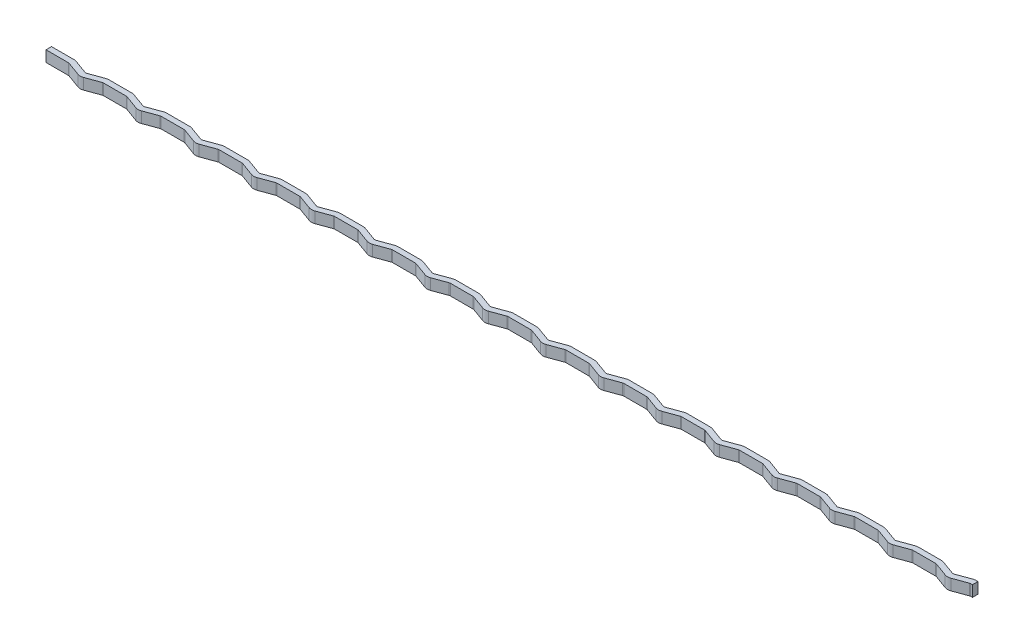
from build123d import *

# Parameters (mm, degrees)
BOSS_EXTRUDE1_DEPTH = 2
LPATTERN1_COUNT     = 16
LPATTERN1_PITCH     = 10.5


with BuildPart() as part:
    # Sketch1 → Boss-Extrude1 (new body)
    with BuildSketch(Plane(origin=(0, 0, 0), x_dir=(1, 0, 0), z_dir=(0, 1, 0))):
        with BuildLine():
            Line((0, -0.5), (4.073673019, -0.5))
            ThreePointArc((4.073673019, -0.5), (4.160497108, -0.507596123), (4.244683091, -0.53015369))
            Line((4.244683091, -0.53015369), (6.736969785, -1.437271862))
            ThreePointArc((6.736969785, -1.437271862), (7.25, -1.52773293), (7.763030215, -1.437271862))
            Line((7.763030215, -1.437271862), (10.255316909, -0.53015369))
            ThreePointArc((10.255316909, -0.53015369), (10.339502892, -0.507596123), (10.426326981, -0.5))
            Line((10.426326981, -0.5), (10.75, -0.5))
            Line((10.75, -0.5), (10.75, 0.5))
            Line((10.75, 0.5), (10.426326981, 0.5))
            ThreePointArc((10.426326981, 0.5), (10.165854714, 0.47721163), (9.913296766, 0.409538931))
            Line((9.913296766, 0.409538931), (7.421010072, -0.497579241))
            ThreePointArc((7.421010072, -0.497579241), (7.25, -0.52773293), (7.078989928, -0.497579241))
            Line((7.078989928, -0.497579241), (4.586703234, 0.409538931))
            ThreePointArc((4.586703234, 0.409538931), (4.334145286, 0.47721163), (4.073673019, 0.5))
            Line((4.073673019, 0.5), (0, 0.5))
            Line((0, 0.5), (0, -0.5))
        make_face()
    boss_extrude1 = extrude(amount=BOSS_EXTRUDE1_DEPTH)

    # LPattern1: Boss-Extrude1 ×16
    with Locations(*[(i * LPATTERN1_PITCH, 0, 0) for i in range(1, LPATTERN1_COUNT)]):
        add(boss_extrude1)


solid = part.part
